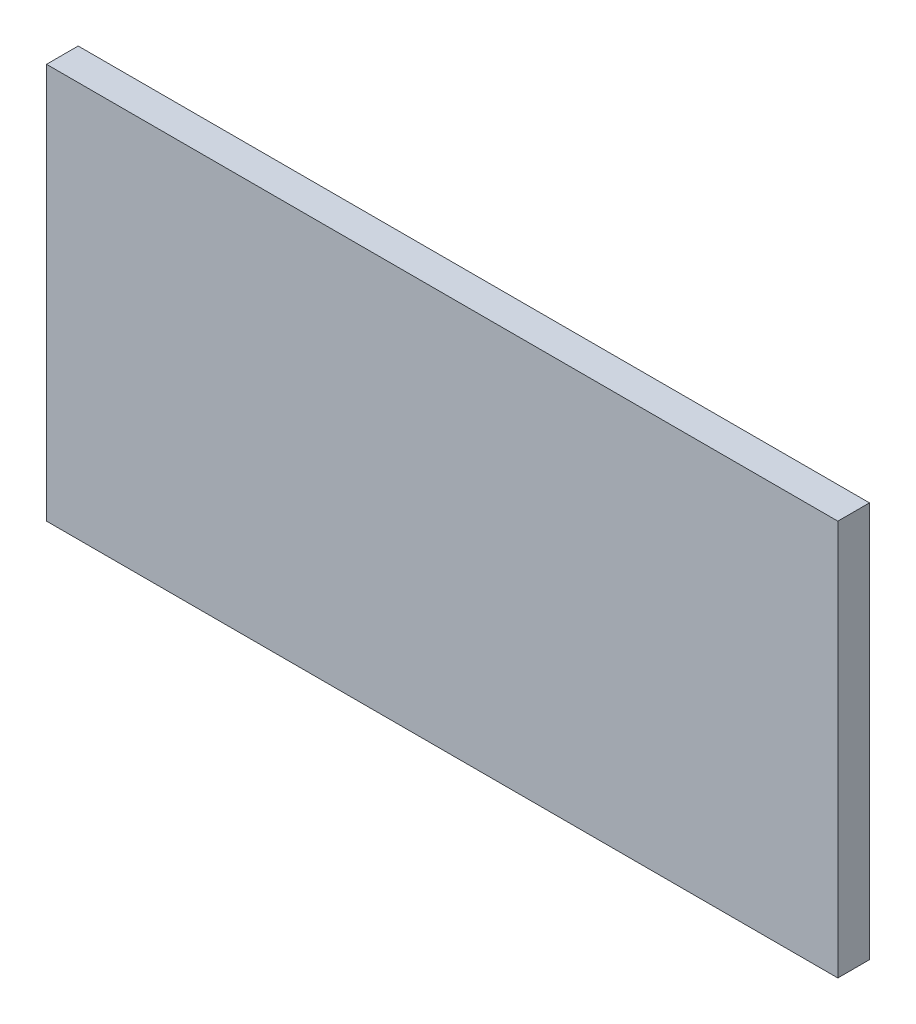
from build123d import *

# Parameters (mm, degrees)
SKETCH1_W           = 500
SKETCH1_H           = 250
BOSS_EXTRUDE1_DEPTH = 20


with BuildPart() as part:
    # Sketch1 → Boss-Extrude1 (new body)
    with BuildSketch(Plane.XY):
        Rectangle(SKETCH1_W, SKETCH1_H)
    extrude(amount=BOSS_EXTRUDE1_DEPTH)


solid = part.part
